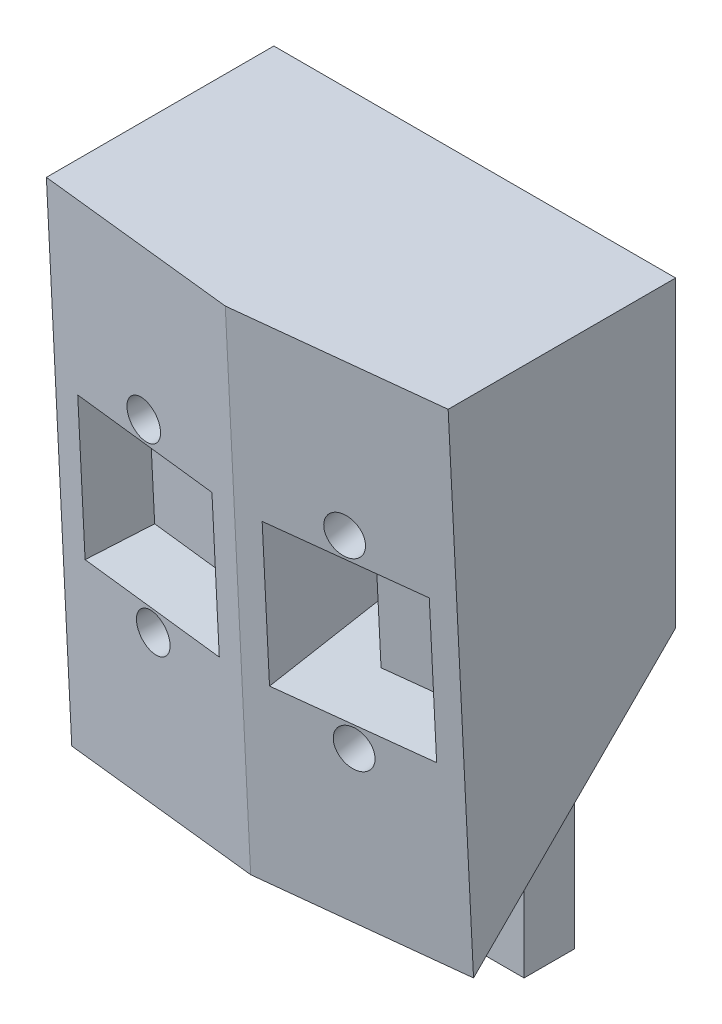
from build123d import *

# Parameters (mm, degrees)
BOSS_EXTRUDE1_DEPTH = 50.8
DRAFT1_ANGLE        = 2.86
CUT_EXTRUDE1_DEPTH  = 10.16
SKETCH3_W           = 20.078449586
SKETCH3_H           = 5.08
BOSS_EXTRUDE2_DEPTH = 12.7
CUT_EXTRUDE2_START  = -28.101341283
SKETCH4_R           = 1.905
SKETCH4_W           = 5.08
SKETCH4_H           = 14.732
CUT_EXTRUDE2_DEPTH  = 34.466005054
SKETCH5_W           = 15.24
SKETCH5_H           = 14.732
CUT_EXTRUDE3_DEPTH  = 6.35


with BuildPart() as part:
    # Sketch1 → Boss-Extrude1 (new body)
    with BuildSketch(Plane(origin=(0, 0, 0), x_dir=(1, 0, 0), z_dir=(0, 1, 0))):
        Polygon((-20.199224793, 2.212174897), (0, 0), (20.199224793, 2.212174897), (20.199224793, 22.532174897), (-20.199224793, 22.532174897), align=None)
    extrude(amount=-BOSS_EXTRUDE1_DEPTH)

    # Draft1
    draft1_faces = [part.faces().sort_by_distance(p)[0] for p in [
        (10.099612396, -25.4, -1.106087448),
        (-10.099612396, -25.4, -1.106087448),
    ]]
    draft(draft1_faces, Plane(origin=(0, -50.8, 0), x_dir=(0, 0, -1), z_dir=(0, -1, 0)), DRAFT1_ANGLE)

    # Sketch2 → Cut-Extrude1 (cut)
    with BuildSketch(Plane.ZY.offset(20.199224793)):
        Polygon((-22.532174897, -30.48), (-2.212174897, -50.8), (-22.532174897, -50.8), align=None)
    cut_extrude1 = extrude(amount=-CUT_EXTRUDE1_DEPTH, mode=Mode.SUBTRACT)

    # Mirror1: Cut-Extrude1 across plane
    add(cut_extrude1.mirror(Plane.ZY), mode=Mode.SUBTRACT)

    # Sketch3 → Boss-Extrude2 (add)
    with BuildSketch(Plane.XZ.offset(50.8)):
        with Locations((0, -19.992174897)):
            Rectangle(SKETCH3_W, SKETCH3_H)
    extrude(amount=BOSS_EXTRUDE2_DEPTH)

    # Sketch4 → Cut-Extrude2 (cut)
    with BuildSketch(Plane(origin=(-0.275601276, -0.126470659, 2.516497283), x_dir=(0.99407118, -0.005457579, 0.108594221), z_dir=(-0.108731274, -0.04989569, 0.992818176)).offset(CUT_EXTRUDE2_START)):
        with Locations((-9.882603301, -15.834429405)):
            Circle(SKETCH4_R)
        with Locations((-9.882603301, -34.884429405)):
            Circle(SKETCH4_R)
        with Locations((-4.802603301, -25.359429405)):
            Rectangle(SKETCH4_W, SKETCH4_H)
    cut_extrude2 = extrude(amount=CUT_EXTRUDE2_DEPTH, mode=Mode.SUBTRACT)

    # Sketch5 → Cut-Extrude3 (cut)
    with BuildSketch(Plane(origin=(-0.275601276, -0.126470659, 2.516497283), x_dir=(0.99407118, -0.005457579, 0.108594221), z_dir=(-0.108731274, -0.04989569, 0.992818176))):
        with Locations((-9.882603301, -25.359429405)):
            Rectangle(SKETCH5_W, SKETCH5_H)
    cut_extrude3 = extrude(amount=-CUT_EXTRUDE3_DEPTH, mode=Mode.SUBTRACT)

    # Mirror2: Cut-Extrude2, Cut-Extrude3 across plane
    add(cut_extrude2.mirror(Plane.ZY), mode=Mode.SUBTRACT)
    add(cut_extrude3.mirror(Plane.ZY), mode=Mode.SUBTRACT)


solid = part.part
